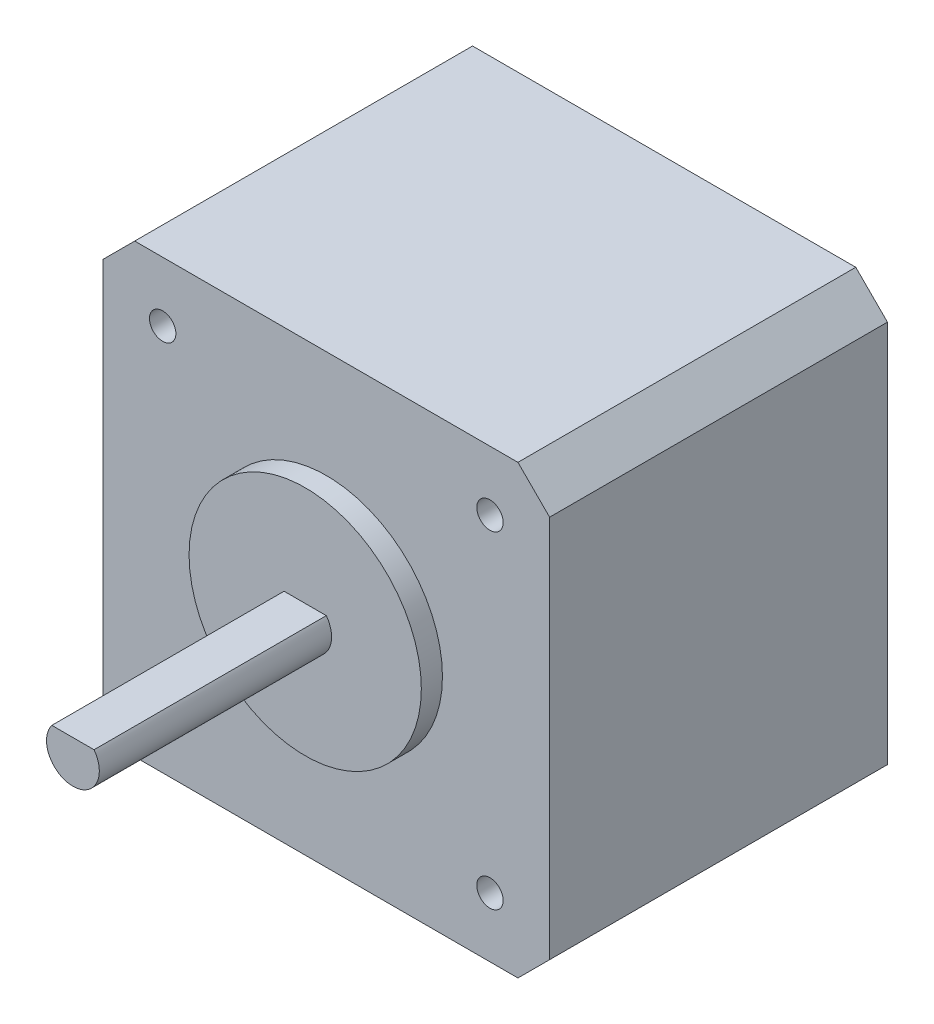
from build123d import *

# Parameters (mm, degrees)
BOSS_EXTRU_1_DEPTH      = 32
ESQUISSE2_R             = 11
BOSS_EXTRU_2_DEPTH      = 2
BOSS_EXTRU_3_DEPTH      = 22
ESQUISSE4_R             = 1.25
ENL_V_MAT_EXTRU_1_DEPTH = 10


with BuildPart() as part:
    # Esquisse1 → Boss.-Extru.1 (new body)
    with BuildSketch(Plane.XY):
        Polygon((21.15, 18.15), (18.15, 21.15), (-18.15, 21.15), (-21.15, 18.15), (-21.15, -18.15), (-18.15, -21.15), (18.15, -21.15), (21.15, -18.15), align=None)
    extrude(amount=BOSS_EXTRU_1_DEPTH)

    # Esquisse2 → Boss.-Extru.2 (add)
    with BuildSketch(Plane.XY.offset(32)):
        Circle(ESQUISSE2_R)
    extrude(amount=BOSS_EXTRU_2_DEPTH)

    # Esquisse3 → Boss.-Extru.3 (add)
    with BuildSketch(Plane.XY.offset(34)):
        with BuildLine():
            Line((-2, 1.5), (2, 1.5))
            ThreePointArc((2, 1.5), (0, -2.5), (-2, 1.5))
        make_face()
    extrude(amount=BOSS_EXTRU_3_DEPTH)

    # Esquisse4 → Enlèv. mat.-Extru.1 (cut)
    with BuildSketch(Plane.XY.offset(32)):
        with Locations((-15.5, 15.5)):
            Circle(ESQUISSE4_R)
        with Locations((15.5, 15.5)):
            Circle(ESQUISSE4_R)
        with Locations((15.5, -15.5)):
            Circle(ESQUISSE4_R)
        with Locations((-15.5, -15.5)):
            Circle(ESQUISSE4_R)
    extrude(amount=-ENL_V_MAT_EXTRU_1_DEPTH, mode=Mode.SUBTRACT)


solid = part.part
